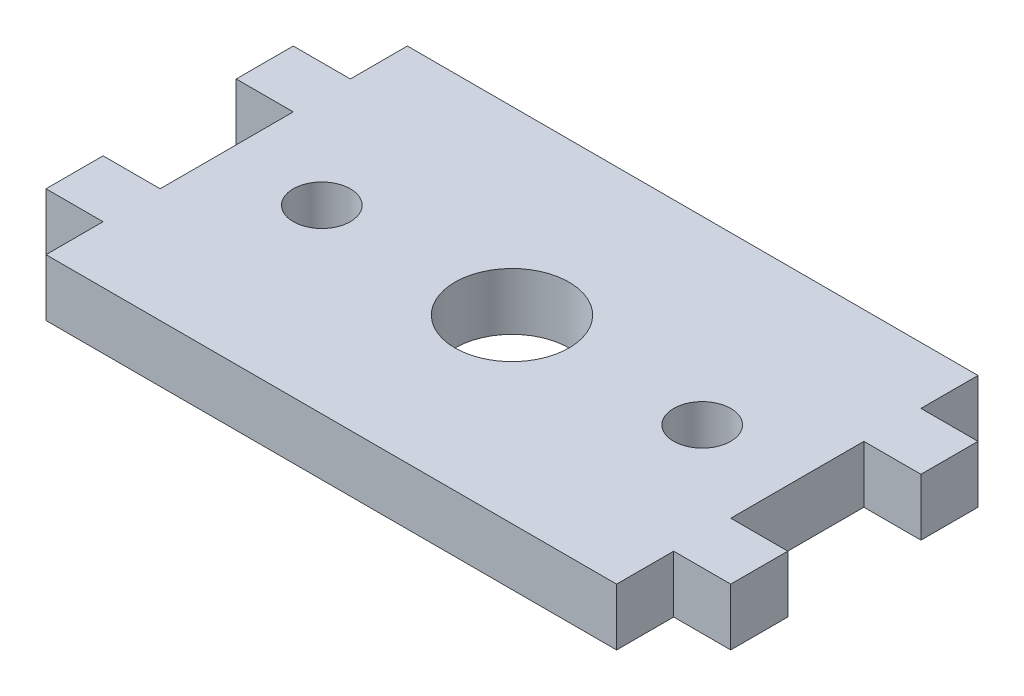
from build123d import *

# Parameters (mm, degrees)
SKETCH1_R           = 3
SKETCH1_R_2         = 1.5
BOSS_EXTRUDE1_DEPTH = 3


with BuildPart() as part:
    # Sketch1 → Boss-Extrude1 (new body)
    with BuildSketch(Plane(origin=(0, 0, 0), x_dir=(1, 0, 0), z_dir=(0, 1, 0))):
        Polygon((-42.867412192, 7), (-42.867412192, 10), (-39.867412192, 10), (-39.867412192, 13), (-9.867412192, 13), (-9.867412192, 10), (-6.867412192, 10), (-6.867412192, 7), (-9.867412192, 7), (-9.867412192, 0), (-6.867412192, 0), (-6.867412192, -3), (-9.867412192, -3), (-9.867412192, -6), (-39.867412192, -6), (-39.867412192, -3), (-42.867412192, -3), (-42.867412192, 0), (-39.867412192, 0), (-39.867412192, 7), align=None)
        with Locations((-24.867412192, 3.5)):
            Circle(SKETCH1_R, mode=Mode.SUBTRACT)
        with Locations((-34.867412192, 3.5)):
            Circle(SKETCH1_R_2, mode=Mode.SUBTRACT)
        with Locations((-14.867412192, 3.5)):
            Circle(SKETCH1_R_2, mode=Mode.SUBTRACT)
    extrude(amount=BOSS_EXTRUDE1_DEPTH)


solid = part.part
